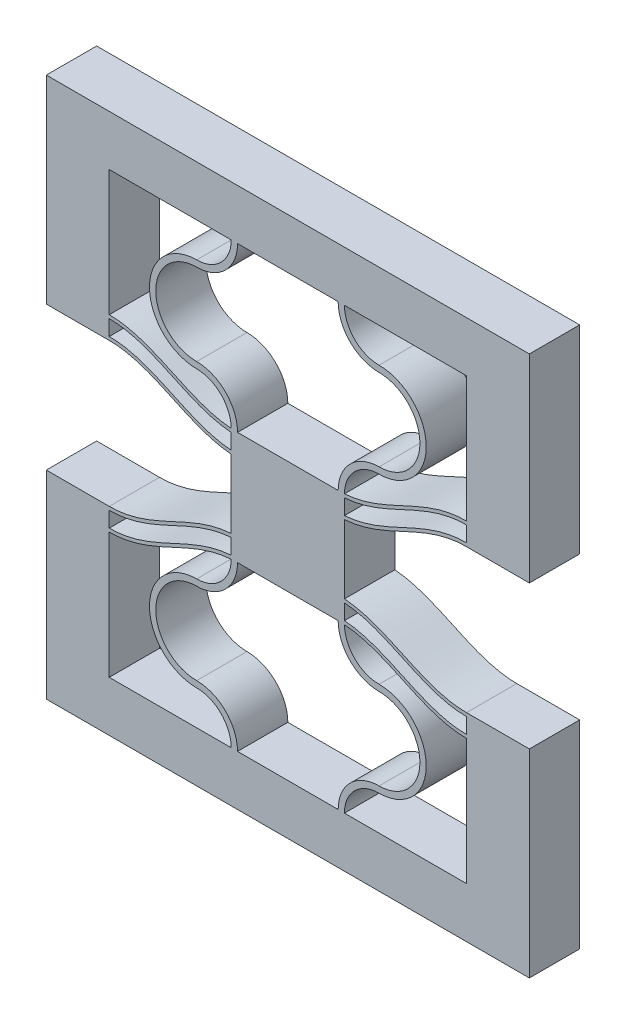
from build123d import *

# Parameters (mm, degrees)
BOSS_EXTRUDE1_DEPTH = 4
SKETCH4_W           = 1.000114629
SKETCH4_H           = 4
BOSS_EXTRUDE2_DEPTH = 1.5
SKETCH7_W           = 4
SKETCH7_H           = 4
SKETCH7_H_2         = 8.964490664
BOSS_EXTRUDE3_DEPTH = 4


with BuildPart() as part:
    # Sketch1 → Boss-Extrude1 (new body)
    with BuildSketch(Plane.XY):
        with BuildLine():
            add(Edge.make_bspline(
                [(10.700057309, 14.752245332), (10.772391737, 14.747118446), (11.041607524, 14.724381435), (11.505662437, 14.66184152), (12.306665151, 14.487463939), (13.203923987, 14.189623446), (13.985261284, 13.867575436), (14.665968761, 13.56222259), (15.11484806, 13.355710774), (15.47349126, 13.189665314), (15.83269613, 13.02440982), (16.192673631, 12.861648364), (16.626765751, 12.671733956), (17.13586524, 12.46101122), (17.746893049, 12.234075534), (18.367861759, 12.044347898), (18.92798815, 11.914661227), (19.412184864, 11.834241004), (19.763394722, 11.795860067), (20.042497274, 11.776485201), (20.274552652, 11.770926539), (20.358572634, 11.770000157), (20.4, 11.770000157)],
                knots=[0.519564495, 0.519564495, 0.519564495, 0.519564495, 0.519564495, 0.53090372, 0.561807491, 0.592711256, 0.647556688, 0.678460478, 0.693912373, 0.709364268, 0.724816163, 0.740268058, 0.755719952, 0.771171847, 0.798845035, 0.826518222, 0.857421936, 0.872873803, 0.888325669, 0.903777538, 0.911503473, 0.919229407, 0.919229407, 0.919229407, 0.919229407, 0.919229407], degree=4))
            Line((10.700057309, 14.752245332), (10.700057309, 15.982245332))
            Line((10.700057309, 15.982245332), (9.69994268, 15.982245332))
            Line((9.69994268, 15.982245332), (9.69994268, 14.752245332))
            add(Edge.make_bspline(
                [(0, 11.770000157), (0.041427365, 11.770000157), (0.125886516, 11.770926499), (0.300180413, 11.775095025), (0.495378064, 11.786173025), (0.689785531, 11.802695876), (0.887372834, 11.8245536), (1.131893692, 11.858366882), (1.42411245, 11.908988377), (1.76233195, 11.981841602), (2.220406977, 12.10200414), (2.746519587, 12.268550364), (3.263678987, 12.461012972), (3.773495672, 12.671732903), (4.207178553, 12.861648968), (4.567395316, 13.024409445), (4.926458292, 13.189665522), (5.285174696, 13.35571068), (5.734019803, 13.562222637), (6.41474716, 13.8675754), (7.196070942, 14.189623468), (8.093337192, 14.487463927), (8.894336998, 14.661841525), (9.358392185, 14.724381436), (9.627608193, 14.747118446), (9.69994268, 14.752245332)],
                knots=[0.080770593, 0.080770593, 0.080770593, 0.080770593, 0.080770593, 0.088496527, 0.096222462, 0.103948397, 0.111674331, 0.119400264, 0.127126197, 0.142578064, 0.158029921, 0.173481778, 0.201154965, 0.228828153, 0.244280048, 0.259731942, 0.275183837, 0.290635732, 0.306087627, 0.321539522, 0.352443312, 0.407288744, 0.438192509, 0.46909628, 0.480435506, 0.480435506, 0.480435506, 0.480435506, 0.480435506], degree=4))
            Line((0, 11.770000157), (-5.000000005, 11.770000157))
            Line((-5.000000005, 11.770000157), (-5.000000005, -4))
            Line((-5.000000005, -4), (25.400000005, -4))
            Line((25.400000005, -4), (25.400000005, 11.770000157))
            Line((25.400000005, 11.770000157), (20.4, 11.770000157))
        make_face()
        with BuildLine():
            Line((9.69994268, 14.482245332), (9.69994268, 13.252245332))
            add(Edge.make_bspline(
                [(0, 10.270000157), (0.041427365, 10.270000157), (0.125886516, 10.270926499), (0.300180413, 10.275095025), (0.495378064, 10.286173025), (0.689785531, 10.302695876), (0.887372834, 10.3245536), (1.131893691, 10.358366882), (1.42411245, 10.408988377), (1.76233195, 10.481841602), (2.220406977, 10.60200414), (2.746519587, 10.768550364), (3.263678987, 10.961012972), (3.773495672, 11.171732903), (4.207178553, 11.361648968), (4.567395316, 11.524409445), (4.926458292, 11.689665522), (5.285174696, 11.85571068), (5.734019803, 12.062222637), (6.41474716, 12.3675754), (7.196070942, 12.689623468), (8.093337192, 12.987463927), (8.894336998, 13.161841525), (9.358392185, 13.224381436), (9.627608193, 13.247118446), (9.69994268, 13.252245332)],
                knots=[0.080770593, 0.080770593, 0.080770593, 0.080770593, 0.080770593, 0.088496527, 0.096222462, 0.103948397, 0.111674331, 0.119400264, 0.127126197, 0.142578064, 0.158029921, 0.173481778, 0.201154965, 0.228828153, 0.244280048, 0.259731942, 0.275183837, 0.290635732, 0.306087627, 0.321539522, 0.352443312, 0.407288744, 0.438192509, 0.46909628, 0.480435506, 0.480435506, 0.480435506, 0.480435506, 0.480435506], degree=4))
            Line((0, 10.270000157), (0, 11.500000157))
            add(Edge.make_bspline(
                [(0, 11.500000157), (0.041427365, 11.500000157), (0.125886516, 11.500926499), (0.300180413, 11.505095025), (0.495378064, 11.516173025), (0.689785532, 11.532695876), (0.887372834, 11.5545536), (1.131893692, 11.588366882), (1.42411245, 11.638988377), (1.76233195, 11.711841602), (2.220406977, 11.83200414), (2.746519587, 11.998550364), (3.263678987, 12.191012972), (3.773495672, 12.401732903), (4.207178553, 12.591648968), (4.567395316, 12.754409445), (4.926458292, 12.919665522), (5.285174697, 13.08571068), (5.734019803, 13.292222637), (6.41474716, 13.5975754), (7.196070942, 13.919623468), (8.093337192, 14.217463927), (8.894336998, 14.391841525), (9.358392185, 14.454381436), (9.627608193, 14.477118446), (9.69994268, 14.482245332)],
                knots=[0.080770593, 0.080770593, 0.080770593, 0.080770593, 0.080770593, 0.088496527, 0.096222462, 0.103948397, 0.111674331, 0.119400264, 0.127126197, 0.142578064, 0.158029921, 0.173481778, 0.201154965, 0.228828153, 0.244280048, 0.259731942, 0.275183837, 0.290635732, 0.306087627, 0.321539522, 0.352443312, 0.407288744, 0.438192509, 0.46909628, 0.480435506, 0.480435506, 0.480435506, 0.480435506, 0.480435506], degree=4))
        make_face(mode=Mode.SUBTRACT)
        with BuildLine():
            Line((10.700057309, 13.252245332), (10.700057309, 14.482245332))
            add(Edge.make_bspline(
                [(10.700057309, 14.482245332), (10.772391737, 14.477118446), (11.041607524, 14.454381435), (11.505662437, 14.39184152), (12.306665151, 14.217463939), (13.203923987, 13.919623446), (13.985261285, 13.597575436), (14.665968762, 13.29222259), (15.11484806, 13.085710774), (15.47349126, 12.919665314), (15.83269613, 12.75440982), (16.192673631, 12.591648364), (16.626765751, 12.401733956), (17.13586524, 12.19101122), (17.746893049, 11.964075534), (18.367861759, 11.774347898), (18.92798815, 11.644661227), (19.412184864, 11.564241004), (19.763394722, 11.525860067), (20.042497274, 11.506485201), (20.274552652, 11.500926539), (20.358572634, 11.500000157), (20.4, 11.500000157)],
                knots=[0.519564495, 0.519564495, 0.519564495, 0.519564495, 0.519564495, 0.53090372, 0.561807491, 0.592711256, 0.647556688, 0.678460478, 0.693912373, 0.709364268, 0.724816163, 0.740268058, 0.755719952, 0.771171847, 0.798845035, 0.826518222, 0.857421936, 0.872873803, 0.888325669, 0.903777538, 0.911503473, 0.919229407, 0.919229407, 0.919229407, 0.919229407, 0.919229407], degree=4))
            Line((20.4, 11.500000157), (20.4, 10.270000157))
            add(Edge.make_bspline(
                [(10.700057309, 13.252245332), (10.772391737, 13.247118446), (11.041607524, 13.224381435), (11.505662437, 13.16184152), (12.306665151, 12.987463939), (13.203923987, 12.689623446), (13.985261284, 12.367575436), (14.665968761, 12.06222259), (15.11484806, 11.855710774), (15.473491259, 11.689665314), (15.83269613, 11.52440982), (16.192673631, 11.361648364), (16.626765751, 11.171733956), (17.13586524, 10.96101122), (17.746893049, 10.734075534), (18.367861759, 10.544347898), (18.92798815, 10.414661227), (19.412184863, 10.334241004), (19.763394722, 10.295860067), (20.042497274, 10.276485201), (20.274552652, 10.270926539), (20.358572634, 10.270000157), (20.4, 10.270000157)],
                knots=[0.519564495, 0.519564495, 0.519564495, 0.519564495, 0.519564495, 0.53090372, 0.561807491, 0.592711256, 0.647556688, 0.678460478, 0.693912373, 0.709364268, 0.724816163, 0.740268058, 0.755719952, 0.771171847, 0.798845035, 0.826518222, 0.857421936, 0.872873803, 0.888325669, 0.903777538, 0.911503473, 0.919229407, 0.919229407, 0.919229407, 0.919229407, 0.919229407], degree=4))
        make_face(mode=Mode.SUBTRACT)
        with BuildLine():
            Line((0, 0), (0, 10.000000157))
            add(Edge.make_bspline(
                [(0, 10.000000157), (0.041427365, 10.000000157), (0.125886516, 10.000926499), (0.300180413, 10.005095025), (0.495378064, 10.016173025), (0.689785531, 10.032695876), (0.887372834, 10.0545536), (1.131893691, 10.088366882), (1.42411245, 10.138988377), (1.76233195, 10.211841602), (2.220406977, 10.33200414), (2.746519587, 10.498550364), (3.263678987, 10.691012972), (3.773495672, 10.901732903), (4.207178553, 11.091648968), (4.567395316, 11.254409445), (4.926458292, 11.419665522), (5.285174696, 11.58571068), (5.734019803, 11.792222637), (6.41474716, 12.0975754), (7.196070942, 12.419623468), (8.093337192, 12.717463927), (8.894336998, 12.891841525), (9.358392185, 12.954381436), (9.627608193, 12.977118446), (9.69994268, 12.982245332)],
                knots=[0.080770593, 0.080770593, 0.080770593, 0.080770593, 0.080770593, 0.088496527, 0.096222462, 0.103948397, 0.111674331, 0.119400264, 0.127126197, 0.142578064, 0.158029921, 0.173481778, 0.201154965, 0.228828153, 0.244280048, 0.259731942, 0.275183837, 0.290635732, 0.306087627, 0.321539522, 0.352443312, 0.407288744, 0.438192509, 0.46909628, 0.480435506, 0.480435506, 0.480435506, 0.480435506, 0.480435506], degree=4))
            ThreePointArc((9.69994268, 12.982245332), (8.888256255, 11.049189228), (6.949999994, 10.25))
            ThreePointArc((6.949999994, 10.25), (3.199999994, 6.5), (6.949999994, 2.75))
            ThreePointArc((6.949999994, 2.75), (8.894543643, 1.944543648), (9.699999994, 0))
            Line((9.699999994, 0), (0, 0))
        make_face(mode=Mode.SUBTRACT)
        with BuildLine():
            ThreePointArc((6.949999994, 9.75), (9.248097033, 10.701902961), (10.199999994, 13))
            ThreePointArc((10.199999994, 13), (11.151902955, 10.701902961), (13.449999994, 9.75))
            ThreePointArc((13.449999994, 9.75), (16.699999994, 6.5), (13.449999994, 3.25))
            ThreePointArc((13.449999994, 3.25), (11.151902955, 2.298097039), (10.199999994, 0))
            ThreePointArc((10.199999994, 0), (9.248097033, 2.298097039), (6.949999994, 3.25))
            ThreePointArc((6.949999994, 3.25), (3.699999994, 6.5), (6.949999994, 9.75))
        make_face(mode=Mode.SUBTRACT)
        with BuildLine():
            ThreePointArc((13.449999994, 10.25), (11.511743734, 11.049189228), (10.700057309, 12.982245332))
            add(Edge.make_bspline(
                [(10.700057309, 12.982245332), (10.772391737, 12.977118446), (11.041607524, 12.954381435), (11.505662437, 12.89184152), (12.306665151, 12.717463939), (13.203923987, 12.419623446), (13.985261284, 12.097575436), (14.665968761, 11.79222259), (15.11484806, 11.585710774), (15.473491259, 11.419665314), (15.83269613, 11.25440982), (16.192673631, 11.091648364), (16.626765751, 10.901733956), (17.13586524, 10.69101122), (17.746893049, 10.464075534), (18.367861759, 10.274347898), (18.92798815, 10.144661227), (19.412184863, 10.064241004), (19.763394722, 10.025860067), (20.042497274, 10.006485201), (20.274552652, 10.000926539), (20.358572634, 10.000000157), (20.4, 10.000000157)],
                knots=[0.519564495, 0.519564495, 0.519564495, 0.519564495, 0.519564495, 0.53090372, 0.561807491, 0.592711256, 0.647556688, 0.678460478, 0.693912373, 0.709364268, 0.724816163, 0.740268058, 0.755719952, 0.771171847, 0.798845035, 0.826518222, 0.857421936, 0.872873803, 0.888325669, 0.903777538, 0.911503473, 0.919229407, 0.919229407, 0.919229407, 0.919229407, 0.919229407], degree=4))
            Line((20.4, 10.000000157), (20.4, 0))
            Line((20.4, 0), (10.699999994, 0))
            ThreePointArc((10.699999994, 0), (11.505456346, 1.944543648), (13.449999994, 2.75))
            ThreePointArc((13.449999994, 2.75), (17.199999994, 6.5), (13.449999994, 10.25))
        make_face(mode=Mode.SUBTRACT)
    extrude(amount=BOSS_EXTRUDE1_DEPTH)

    # Sketch4 → Boss-Extrude2 (add)
    with BuildSketch(Plane(origin=(0, 15.982245332, 0), x_dir=(1, 0, 0), z_dir=(0, 1, 0))):
        with Locations((10.199999995, -2)):
            Rectangle(SKETCH4_W, SKETCH4_H)
    extrude(amount=BOSS_EXTRUDE2_DEPTH)

    # Mirror3: part across plane


with BuildPart() as part_1:
    add(part.part)
    add(part.part.mirror(Plane.ZX.offset(17.482245332)))

    # Split2
    split(bisect_by=Plane(origin=(10.199999994, 0, 0), x_dir=(0, -1, 0), z_dir=(-1, 0, 0)), keep=Keep.BOTTOM)

    # Sketch7 → Boss-Extrude3 (add)
    with BuildSketch(Plane.ZY.offset(-10.199999994)):
        with Locations((2, 36.964490664)):
            Rectangle(SKETCH7_W, SKETCH7_H)
        with Locations((2, 17.482245332)):
            Rectangle(SKETCH7_W, SKETCH7_H_2)
        with Locations((2, -2)):
            Rectangle(SKETCH7_W, SKETCH7_H)
    extrude(amount=BOSS_EXTRUDE3_DEPTH)

    # Mirror2: part across plane


with BuildPart() as part_2:
    add(part_1.part)
    add(part_1.part.mirror(Plane.ZY.offset(-6.199999994)))


solid = part_2.part
